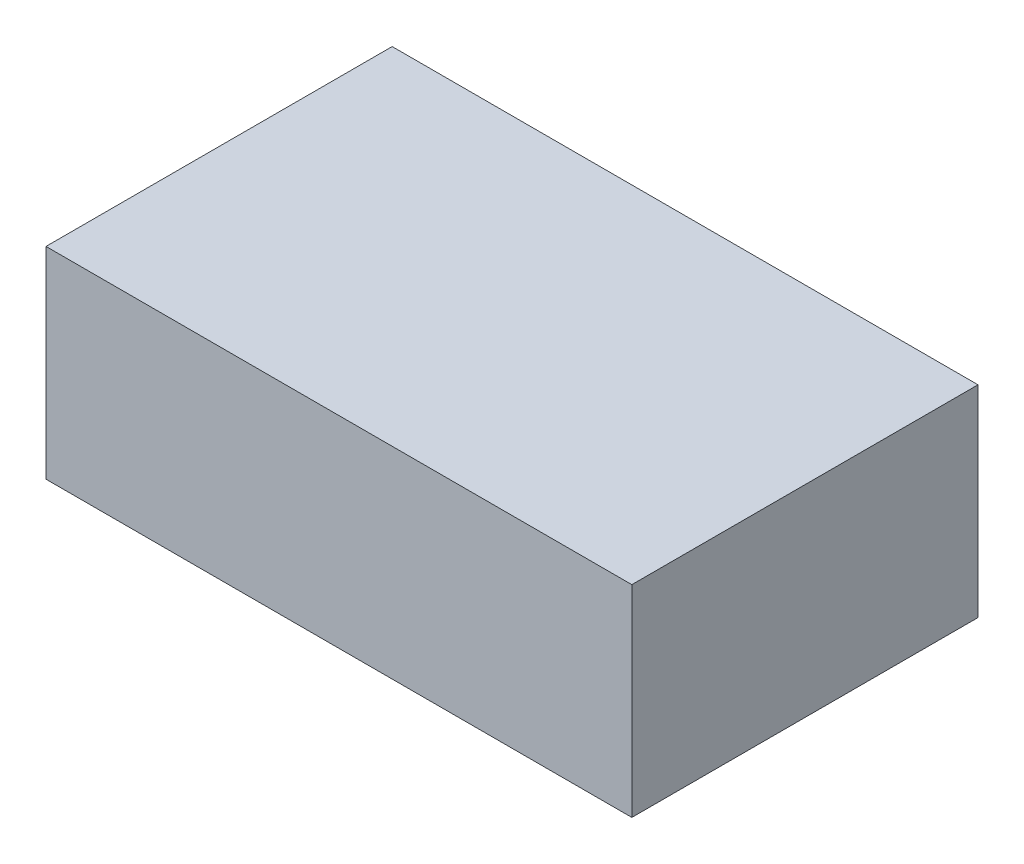
from build123d import *

# Parameters (mm, degrees)
SKETCH_1_W      = 154
SKETCH_1_H      = 91
EXTRUDE_1_DEPTH = 53


with BuildPart() as part:
    # 草图1 → 凸台-拉伸1 (new body)
    with BuildSketch(Plane(origin=(0, 0, 0), x_dir=(1, 0, 0), z_dir=(0, 1, 0))):
        Rectangle(SKETCH_1_W, SKETCH_1_H)
    extrude(amount=EXTRUDE_1_DEPTH)


solid = part.part
